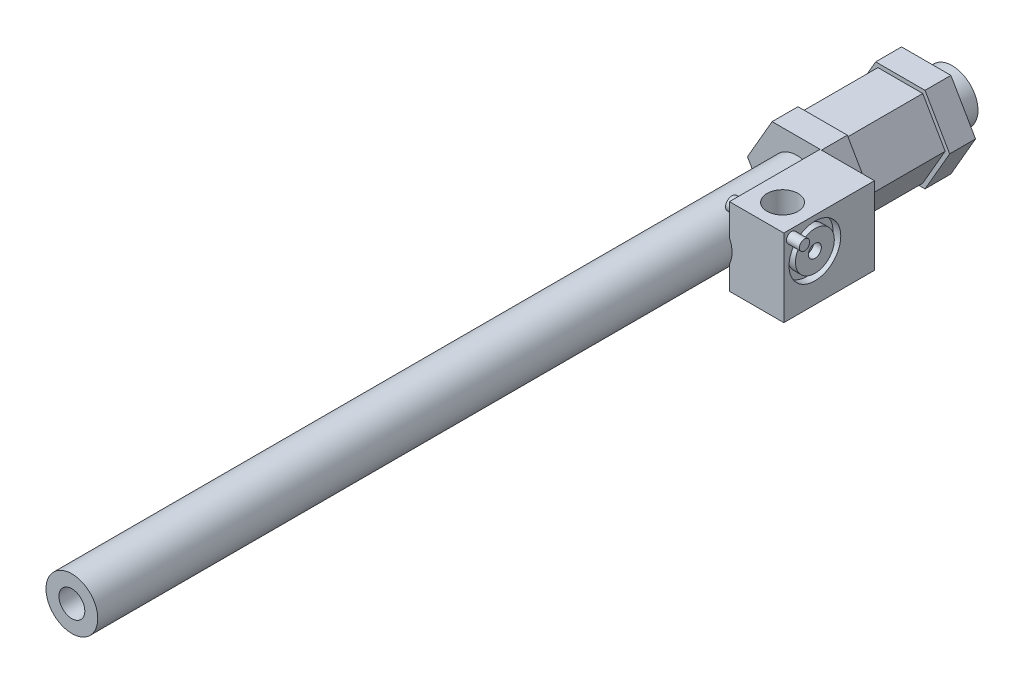
from build123d import *

# Parameters (mm, degrees)
SKETCH1_R            = 10
BOSS_EXTRUDE1_DEPTH  = 340
SKETCH2_R            = 5
CUT_EXTRUDE1_DEPTH   = 330
BOSS_EXTRUDE2_START  = -10
SKETCH3_R            = 10
BOSS_EXTRUDE2_DEPTH  = 50
BOSS_EXTRUDE3_DEPTH  = 10
BOSS_EXTRUDE4_START  = -40
BOSS_EXTRUDE4_DEPTH  = 10
BOSS_EXTRUDE6_START  = 10
SKETCH5_W            = 35
SKETCH5_H            = 30
BOSS_EXTRUDE6_DEPTH  = 10
SKETCH6_W            = 35
SKETCH6_H            = 30
BOSS_EXTRUDE8_DEPTH  = 11
SKETCH7_R            = 6
CUT_EXTRUDE2_DEPTH   = 21
SKETCH8_R            = 2.5
BOSS_EXTRUDE9_DEPTH  = 4
SKETCH9_R            = 10
SKETCH9_R_2          = 7.5
SKETCH9_R_3          = 2.5
CUT_EXTRUDE3_DEPTH   = 3
SKETCH10_R           = 2
BOSS_EXTRUDE10_DEPTH = 5


with BuildPart() as part:
    # Sketch1 → Boss-Extrude1 (new body)
    with BuildSketch(Plane.XY):
        Circle(SKETCH1_R)
    extrude(amount=BOSS_EXTRUDE1_DEPTH)

    # Sketch2 → Cut-Extrude1 (cut)
    with BuildSketch(Plane.XY.offset(340)):
        Circle(SKETCH2_R)
    extrude(amount=-CUT_EXTRUDE1_DEPTH, mode=Mode.SUBTRACT)

    # Sketch3 → Boss-Extrude2 (add)
    with BuildSketch(Plane(origin=(0, 0, 0), x_dir=(-1, 0, 0), z_dir=(0, 0, -1)).offset(BOSS_EXTRUDE2_START)):
        Polygon((17.320508076, 0), (8.660254038, 15), (-8.660254038, 15), (-17.320508076, 0), (-8.660254038, -15), (8.660254038, -15), align=None)
        Circle(SKETCH3_R, mode=Mode.SUBTRACT)
    extrude(amount=-BOSS_EXTRUDE2_DEPTH)

    # Sketch4 → Boss-Extrude3 (add)
    with BuildSketch(Plane(origin=(0, 0, 10), x_dir=(-1, 0, 0), z_dir=(0, 0, -1))):
        Polygon((-9.526279442, -16.5), (9.526279442, -16.5), (19.052558883, 0), (9.526279442, 16.5), (-9.526279442, 16.5), (-19.052558883, 0), align=None)
        Polygon((8.660254038, 15), (-8.660254038, 15), (-17.320508076, 0), (-8.660254038, -15), (8.660254038, -15), (17.320508076, 0), align=None, mode=Mode.SUBTRACT)
    extrude(amount=-BOSS_EXTRUDE3_DEPTH)

    # Sketch4_2 → Boss-Extrude4 (add)
    with BuildSketch(Plane(origin=(0, 0, 10), x_dir=(-1, 0, 0), z_dir=(0, 0, -1)).offset(BOSS_EXTRUDE4_START)):
        Polygon((-9.526279442, -16.5), (9.526279442, -16.5), (19.052558883, 0), (9.526279442, 16.5), (-9.526279442, 16.5), (-19.052558883, 0), align=None)
        Polygon((8.660254038, 15), (-8.660254038, 15), (-17.320508076, 0), (-8.660254038, -15), (8.660254038, -15), (17.320508076, 0), align=None, mode=Mode.SUBTRACT)
    extrude(amount=-BOSS_EXTRUDE4_DEPTH)



with BuildPart() as body_2:
    # Sketch5 → Boss-Extrude6 (new body)
    with BuildSketch(Plane(origin=(10, 0, 0), x_dir=(0, 0, -1), z_dir=(1, 0, 0)).offset(BOSS_EXTRUDE6_START)):
        with Locations((-77.5, 1.5)):
            Rectangle(SKETCH5_W, SKETCH5_H)
    extrude(amount=BOSS_EXTRUDE6_DEPTH)


with BuildPart() as part_1:
    add(part.part)

    add(body_2.part)  # Boss-Extrude8 merges body 2
    # Sketch6 → Boss-Extrude8 (add)
    with BuildSketch(Plane.ZY.offset(-20)):
        with Locations((77.5, 1.5)):
            Rectangle(SKETCH6_W, SKETCH6_H)
    extrude(amount=BOSS_EXTRUDE8_DEPTH)

    # Sketch7 → Cut-Extrude2 (cut)
    with BuildSketch(Plane(origin=(0, 16.5, 0), x_dir=(1, 0, 0), z_dir=(0, 1, 0))):
        with Locations((19.5, -85)):
            Circle(SKETCH7_R)
    extrude(amount=-CUT_EXTRUDE2_DEPTH, mode=Mode.SUBTRACT)

    # Sketch8 → Boss-Extrude9 (add)
    with BuildSketch(Plane.ZY.offset(-9)):
        with Locations((90, 11.5)):
            Circle(SKETCH8_R)
    extrude(amount=BOSS_EXTRUDE9_DEPTH)

    # Sketch9 → Cut-Extrude3 (cut)
    # profile 1 of 2: a face of its own
    with BuildSketch(Plane(origin=(30, 0, 0), x_dir=(0, 0, -1), z_dir=(1, 0, 0))):
        with Locations((-83, 4.5)):
            Circle(SKETCH9_R)
        with Locations((-83, 4.5)):
            Circle(SKETCH9_R_2, mode=Mode.SUBTRACT)
    # profile 2 of 2: a face of its own
    with BuildSketch(Plane(origin=(30, 0, 0), x_dir=(0, 0, -1), z_dir=(1, 0, 0))):
        with Locations((-83, 4.5)):
            Circle(SKETCH9_R_3)
    extrude(amount=-CUT_EXTRUDE3_DEPTH, mode=Mode.SUBTRACT)

    # Sketch10 → Boss-Extrude10 (add)
    with BuildSketch(Plane(origin=(30, 0, 0), x_dir=(0, 0, -1), z_dir=(1, 0, 0))):
        with Locations((-92, 13.5)):
            Circle(SKETCH10_R)
    extrude(amount=BOSS_EXTRUDE10_DEPTH)


solid = part_1.part
